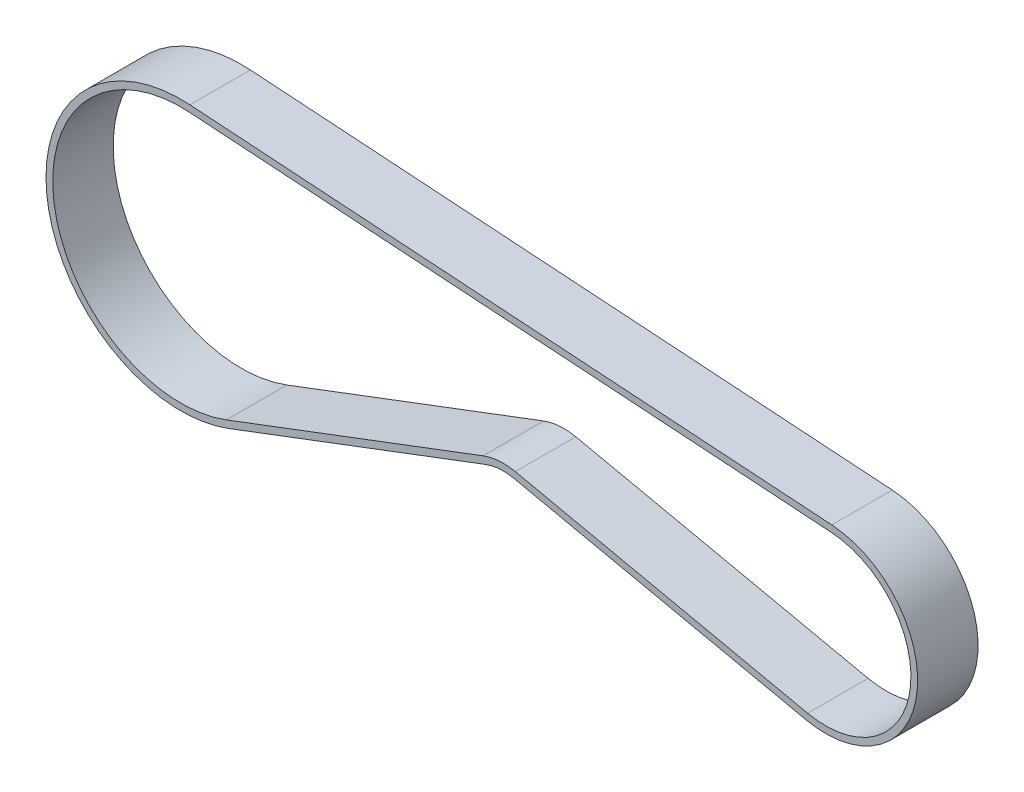
from build123d import *

# Parameters (mm, degrees)
BOSS_EXTRUDE1_DEPTH = 4.5


with BuildPart() as part:
    # Sketch1 → Boss-Extrude1 (new body, symmetric)
    with BuildSketch(Plane.XY):
        with BuildLine():
            Line((0.913333333, 13.669521653), (-94.66, 20.055283593))
            ThreePointArc((-94.66, 20.055283593), (-115.881273585, -2.957187963), (-88.88100799, -18.797072984))
            Line((-88.88100799, -18.797072984), (-50.656340302, -4.32029226))
            ThreePointArc((-50.656340302, -4.32029226), (-48.560454158, -3.855095369), (-46.418644181, -4.002733114))
            Line((-46.418644181, -4.002733114), (-2.888609962, -13.392010024))
            ThreePointArc((-2.888609962, -13.392010024), (13.566762828, -1.906028956), (0.913333333, 13.669521653))
        make_face()
        with BuildLine():
            Line((-51.010519009, -3.385114499), (-89.235186697, -17.861895224))
            ThreePointArc((-89.235186697, -17.861895224), (-114.892155496, -2.810064183), (-94.726666667, 19.05750829))
            Line((-94.726666667, 19.05750829), (0.846666667, 12.67174635))
            ThreePointArc((0.846666667, 12.67174635), (12.576488169, -1.766902755), (-2.67776252, -12.414491044))
            Line((-2.67776252, -12.414491044), (-46.207796739, -3.025214134))
            ThreePointArc((-46.207796739, -3.025214134), (-48.635181379, -2.857891357), (-51.010519009, -3.385114499))
        make_face(mode=Mode.SUBTRACT)
    extrude(amount=BOSS_EXTRUDE1_DEPTH, both=True)


solid = part.part
